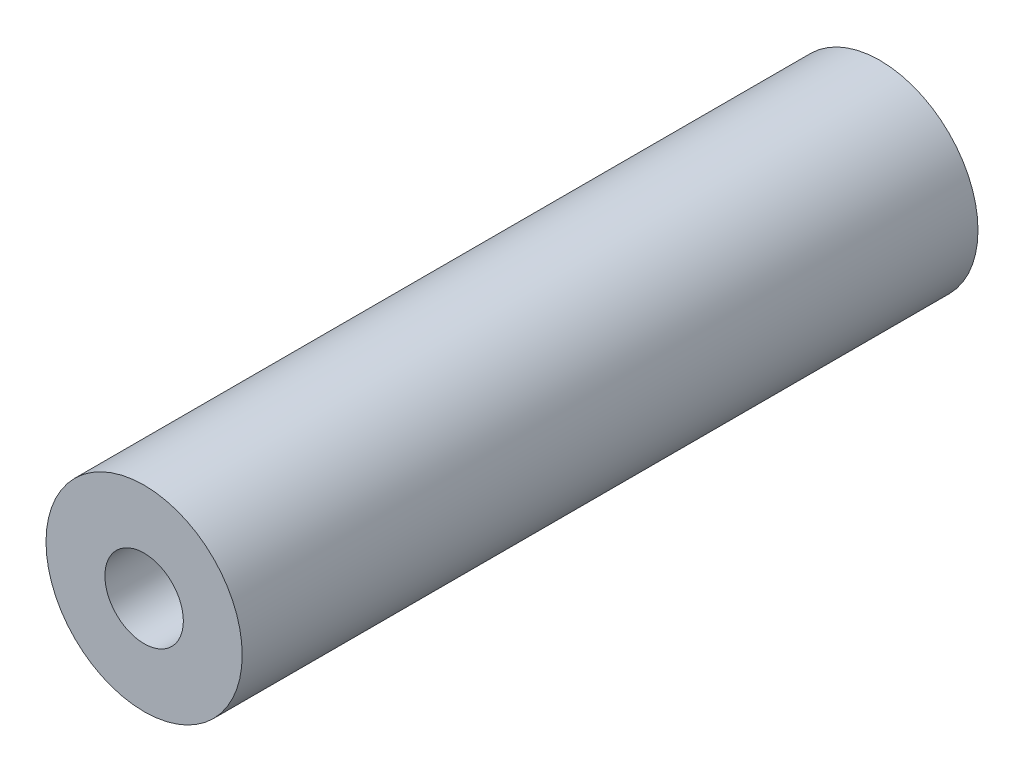
from build123d import *

# Parameters (mm, degrees)
SKETCH1_R           = 5
SKETCH1_R_2         = 2
BOSS_EXTRUDE1_DEPTH = 18.75


with BuildPart() as part:
    # Sketch1 → Boss-Extrude1 (new body, symmetric)
    with BuildSketch(Plane.XY):
        Circle(SKETCH1_R)
        Circle(SKETCH1_R_2, mode=Mode.SUBTRACT)
    extrude(amount=BOSS_EXTRUDE1_DEPTH, both=True)


solid = part.part
